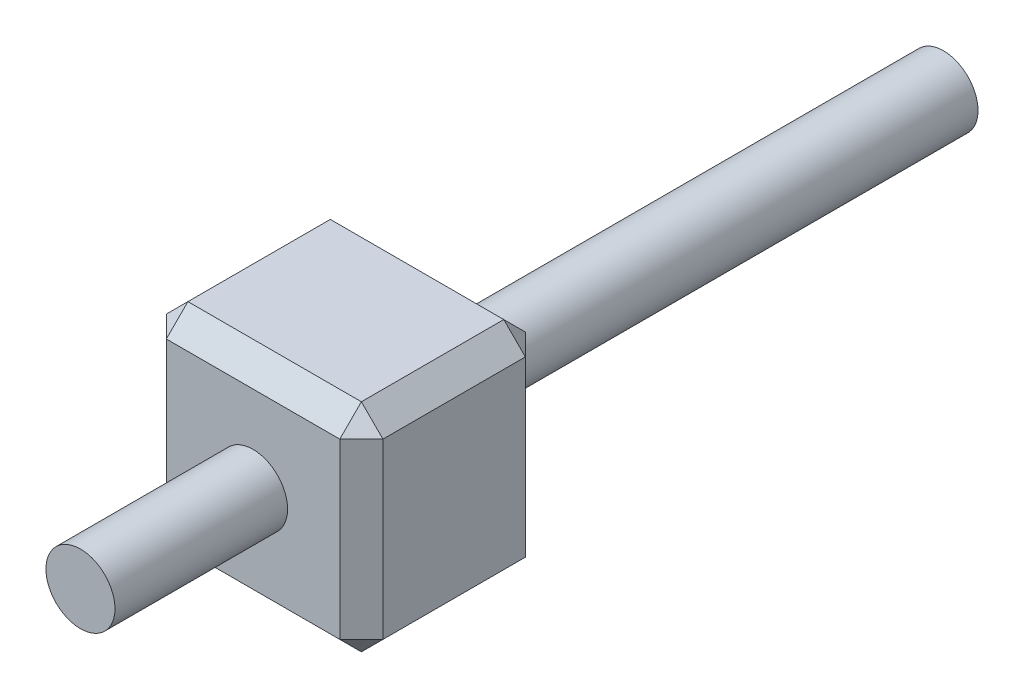
from build123d import *

# Parameters (mm, degrees)
ESQUISSE1_W           = 2.51
ESQUISSE1_H           = 2.51
EXTRUSION1_DEPTH      = 2.15
ESQUISSE2_R           = 0.4
EXTRUSION2_DEPTH      = 2
EXTRUSION2_DEPTH_BACK = 8
CHANFREIN1_SIZE       = 0.25


with BuildPart() as part:
    # Esquisse1 → Extrusion1 (new body)
    with BuildSketch(Plane.XY):
        with Locations((-29.245415213, 23.064714333)):
            Rectangle(ESQUISSE1_W, ESQUISSE1_H)
    extrude(amount=EXTRUSION1_DEPTH)

    # Esquisse2 → Extrusion2 (add, two sides)
    with BuildSketch(Plane.XY.offset(2.15)) as extrusion2_sk:
        with Locations((-29.245415213, 23.064714333)):
            Circle(ESQUISSE2_R)
    extrude(amount=EXTRUSION2_DEPTH)
    extrude(extrusion2_sk.sketch, amount=-EXTRUSION2_DEPTH_BACK)

    # Chanfrein1
    chanfrein1_edges = [part.edges().sort_by_distance(p)[0] for p in [
        (-27.990415213, 23.064714333, 2.15),
        (-29.245415213, 24.319714333, 2.15),
        (-30.500415213, 23.064714333, 2.15),
        (-29.245415213, 24.319714333, 0),
        (-27.990415213, 23.064714333, 0),
        (-29.245415213, 21.809714333, 0),
        (-30.500415213, 23.064714333, 0),
        (-29.245415213, 21.809714333, 2.15),
        (-30.500415213, 24.319714333, 1.075),
        (-27.990415213, 24.319714333, 1.075),
        (-27.990415213, 21.809714333, 1.075),
        (-30.500415213, 21.809714333, 1.075),
    ]]
    chamfer(chanfrein1_edges, length=CHANFREIN1_SIZE)


solid = part.part
